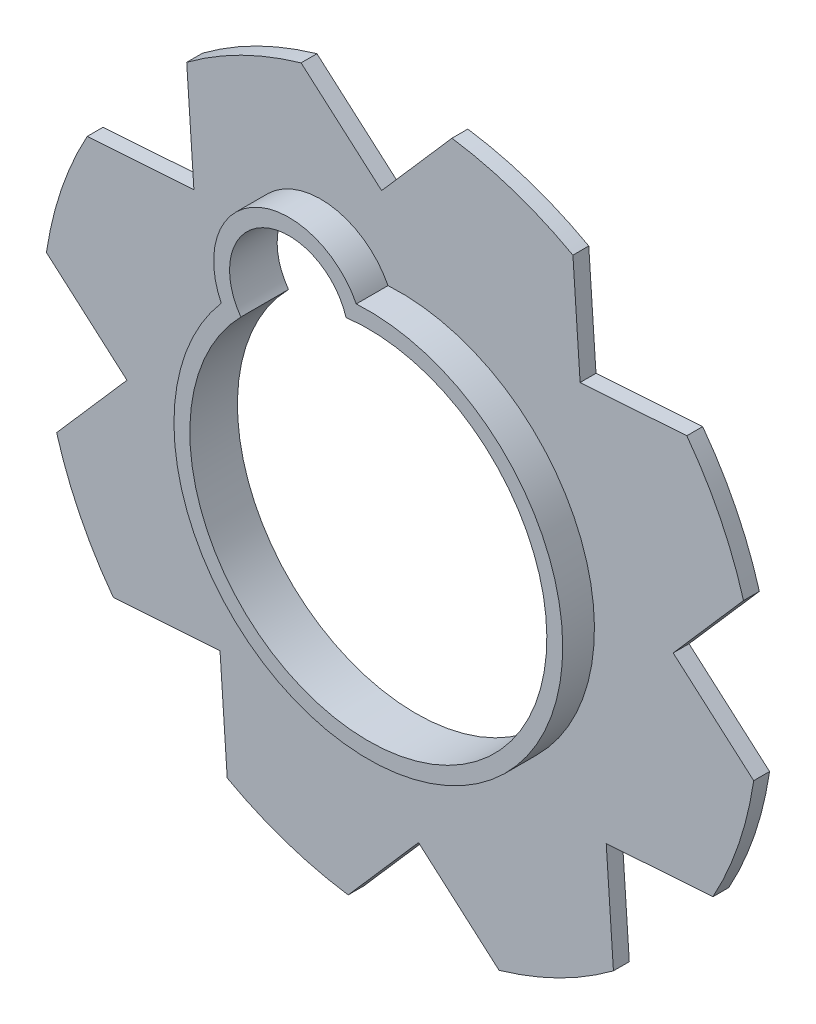
from build123d import *

# Parameters (mm, degrees)
BOSS_EXTRUDE1_DEPTH = 2
BOSS_EXTRUDE2_DEPTH = 4


with BuildPart() as part:
    # Sketch1 → Boss-Extrude1 (new body)
    with BuildSketch(Plane.XY):
        with BuildLine():
            Line((-6.539551855, -44.572825371), (2.326465122, -34.421469464))
            Line((2.326465122, -34.421469464), (12.47782103, -43.287486441))
            ThreePointArc((12.47782103, -43.287486441), (20.007292075, -40.363483049), (26.893585614, -36.141908539))
            Line((26.893585614, -36.141908539), (25.98471374, -22.694595212))
            Line((25.98471374, -22.694595212), (39.432027067, -21.785723338))
            ThreePointArc((39.432027067, -21.785723338), (42.688584475, -14.394000677), (44.572825371, -6.539551855))
            Line((44.572825371, -6.539551855), (34.421469464, 2.326465122))
            Line((34.421469464, 2.326465122), (43.287486441, 12.47782103))
            ThreePointArc((43.287486441, 12.47782103), (40.363483049, 20.007292075), (36.141908539, 26.893585614))
            Line((36.141908539, 26.893585614), (22.694595212, 25.98471374))
            Line((22.694595212, 25.98471374), (21.785723338, 39.432027067))
            ThreePointArc((21.785723338, 39.432027067), (14.394000677, 42.688584475), (6.539551855, 44.572825371))
            Line((6.539551855, 44.572825371), (-2.326465122, 34.421469464))
            Line((-2.326465122, 34.421469464), (-12.47782103, 43.287486441))
            ThreePointArc((-12.47782103, 43.287486441), (-20.007292075, 40.363483049), (-26.893585614, 36.141908539))
            Line((-26.893585614, 36.141908539), (-25.98471374, 22.694595212))
            Line((-25.98471374, 22.694595212), (-39.432027067, 21.785723338))
            ThreePointArc((-39.432027067, 21.785723338), (-42.688584475, 14.394000677), (-44.572825371, 6.539551855))
            Line((-44.572825371, 6.539551855), (-34.421469464, -2.326465122))
            Line((-34.421469464, -2.326465122), (-43.287486441, -12.47782103))
            ThreePointArc((-43.287486441, -12.47782103), (-40.363483049, -20.007292075), (-36.141908539, -26.893585614))
            Line((-36.141908539, -26.893585614), (-22.694595212, -25.98471374))
            Line((-22.694595212, -25.98471374), (-21.785723338, -39.432027067))
            ThreePointArc((-21.785723338, -39.432027067), (-14.394000677, -42.688584475), (-6.539551855, -44.572825371))
        make_face()
        with BuildLine():
            ThreePointArc((-16.063195097, 15.755118637), (9.992543212, -20.159342255), (-2.811608747, 22.323638956))
            ThreePointArc((-2.811608747, 22.323638956), (-13.323390949, 26.879123007), (-16.063195097, 15.755118637))
        make_face(mode=Mode.SUBTRACT)
    extrude(amount=BOSS_EXTRUDE1_DEPTH)

    # Sketch2 → Boss-Extrude2 (add)
    with BuildSketch(Plane.XY.offset(2)):
        with BuildLine():
            ThreePointArc((-1.518157826, 24.452917961), (-14.211617012, 28.671064541), (-18.540947435, 16.015095011))
            ThreePointArc((-18.540947435, 16.015095011), (10.880769275, -21.951283789), (-1.518157826, 24.452917961))
        make_face()
        with BuildLine():
            ThreePointArc((-16.063195097, 15.755118637), (9.992543212, -20.159342255), (-2.811608747, 22.323638956))
            ThreePointArc((-2.811608747, 22.323638956), (-13.323390949, 26.879123007), (-16.063195097, 15.755118637))
        make_face(mode=Mode.SUBTRACT)
    extrude(amount=BOSS_EXTRUDE2_DEPTH)


solid = part.part
